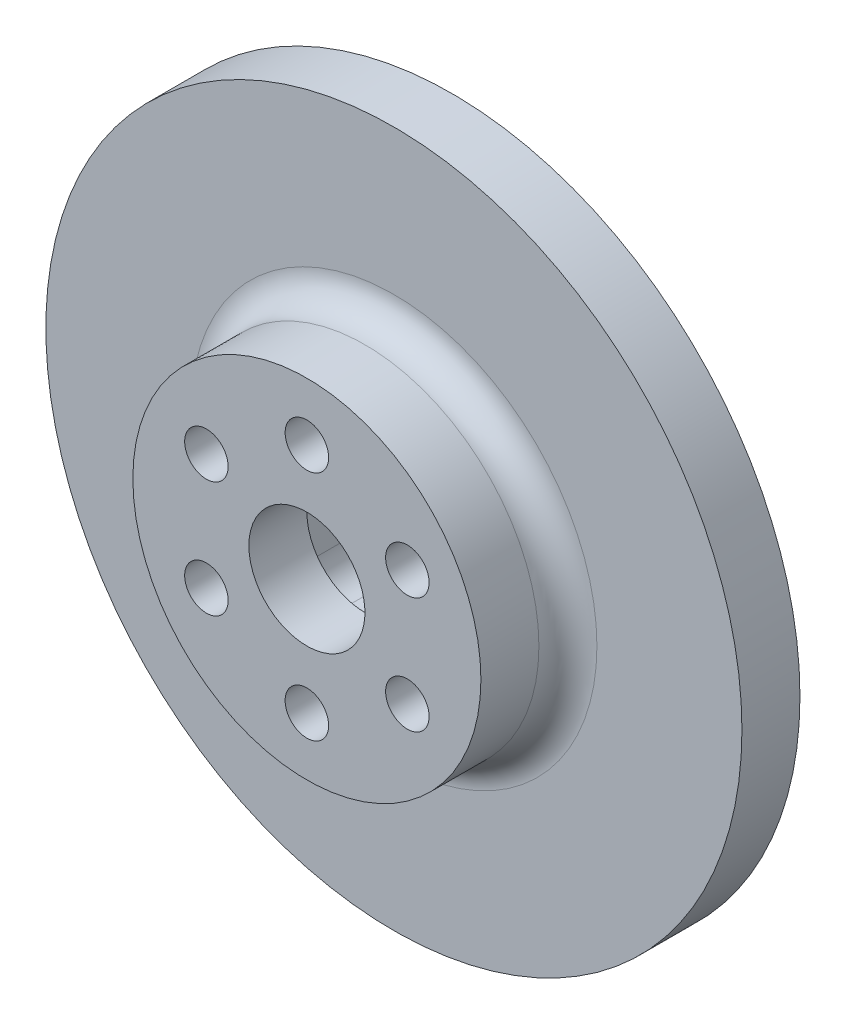
from build123d import *

# Parameters (mm, degrees)
SKETCH1_R           = 38.1
BOSS_EXTRUDE1_DEPTH = 6.35
SKETCH2_R           = 19.05
BOSS_EXTRUDE2_DEPTH = 9.525
CUT_EXTRUDE1_START  = -9.525
CUT_EXTRUDE1_DEPTH  = 9.525
SKETCH4_R           = 6.35
CUT_EXTRUDE2_DEPTH  = 7.35
FILLET2_R           = 3.175
SKETCH7_R           = 2.38125
CUT_EXTRUDE4_DEPTH  = 6.35


with BuildPart() as part:
    # Sketch1 → Boss-Extrude1 (new body)
    with BuildSketch(Plane.XY):
        Circle(SKETCH1_R)
    extrude(amount=BOSS_EXTRUDE1_DEPTH)

    # Sketch2 → Boss-Extrude2 (add)
    with BuildSketch(Plane.XY.offset(6.35)):
        Circle(SKETCH2_R)
    extrude(amount=BOSS_EXTRUDE2_DEPTH)

    # Sketch3 → Cut-Extrude1 (cut)
    with BuildSketch(Plane(origin=(0, 0, 0), x_dir=(-1, 0, 0), z_dir=(0, 0, -1)).offset(CUT_EXTRUDE1_START)):
        with BuildLine():
            Line((-4.7625, -9.525), (4.7625, -9.525))
            ThreePointArc((4.7625, -9.525), (7.00756403, -8.59506403), (7.9375, -6.35))
            Line((7.9375, -6.35), (7.9375, 6.35))
            ThreePointArc((7.9375, 6.35), (7.00756403, 8.59506403), (4.7625, 9.525))
            Line((4.7625, 9.525), (-4.7625, 9.525))
            ThreePointArc((-4.7625, 9.525), (-7.00756403, 8.59506403), (-7.9375, 6.35))
            Line((-7.9375, 6.35), (-7.9375, -6.35))
            ThreePointArc((-7.9375, -6.35), (-7.00756403, -8.59506403), (-4.7625, -9.525))
        make_face()
    extrude(amount=CUT_EXTRUDE1_DEPTH, mode=Mode.SUBTRACT)

    # Sketch4 → Cut-Extrude2 (cut, through all)
    with BuildSketch(Plane(origin=(0, 0, 9.525), x_dir=(-1, 0, 0), z_dir=(0, 0, -1))):
        Circle(SKETCH4_R)
    extrude(amount=-CUT_EXTRUDE2_DEPTH, mode=Mode.SUBTRACT)

    # Fillet2
    fillet2_edges = [part.edges().sort_by_distance(p)[0] for p in [
        (-19.05, 0, 6.35),
    ]]
    fillet(fillet2_edges, radius=FILLET2_R)

    # Sketch7 → Cut-Extrude4 (cut)
    with BuildSketch(Plane.XY.offset(15.875)):
        with Locations((0, 12.7)):
            Circle(SKETCH7_R)
        with Locations((10.998522628, 6.35)):
            Circle(SKETCH7_R)
        with Locations((10.998522628, -6.35)):
            Circle(SKETCH7_R)
        with Locations((0, -12.7)):
            Circle(SKETCH7_R)
        with Locations((-10.998522628, -6.35)):
            Circle(SKETCH7_R)
        with Locations((-10.998522628, 6.35)):
            Circle(SKETCH7_R)
    extrude(amount=-CUT_EXTRUDE4_DEPTH, mode=Mode.SUBTRACT)


solid = part.part
